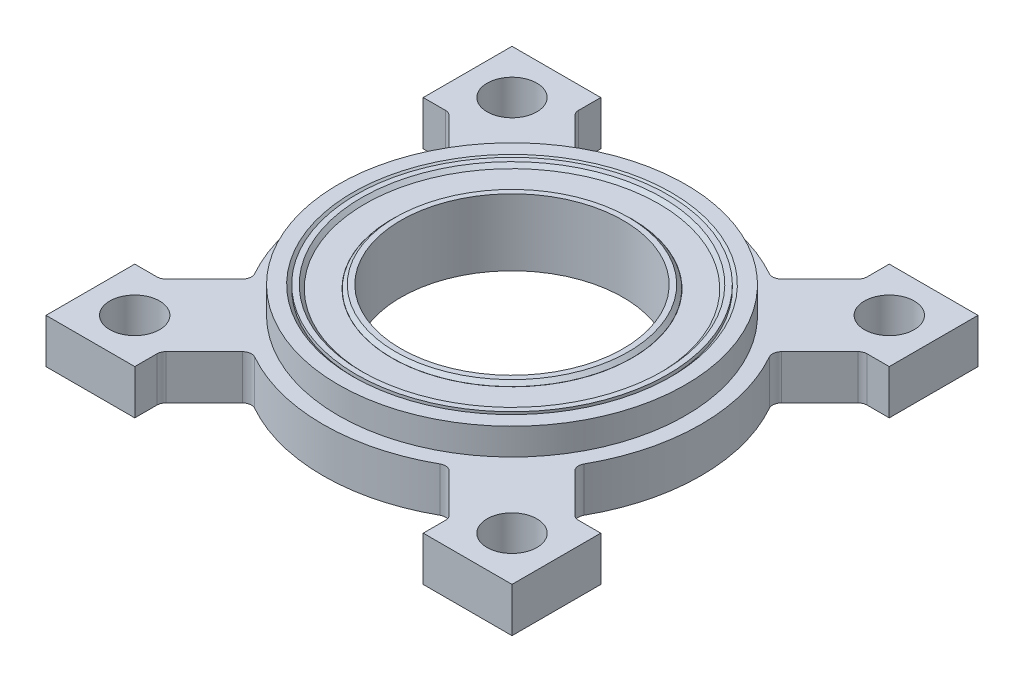
from build123d import *

# Parameters (mm, degrees)
SKETCH1_R           = 11.1252
SKETCH1_R_2         = 1.778
BOSS_EXTRUDE1_DEPTH = 3.175
SKETCH2_R           = 12.3952
SKETCH2_R_2         = 11.1252
BOSS_EXTRUDE2_DEPTH = 1.905
CHAMFER1_SIZE       = 0.254
SKETCH3_R           = 11.1252
SKETCH3_R_2         = 10.4902
BOSS_EXTRUDE3_DEPTH = 4.7625
CHAMFER2_SIZE       = 0.254
SKETCH4_R           = 10.4902
SKETCH4_R_2         = 8.5852
BOSS_EXTRUDE4_DEPTH = 4.2545
SKETCH5_R           = 8.5725
SKETCH5_R_2         = 7.9375
BOSS_EXTRUDE5_DEPTH = 4.7625
CHAMFER3_SIZE       = 0.254


with BuildPart() as part:
    # Sketch1 → Boss-Extrude1 (new body)
    with BuildSketch(Plane(origin=(0, 0, 0), x_dir=(1, 0, 0), z_dir=(0, 1, 0))):
        with BuildLine():
            Line((-10.2997, 16.637), (-10.2997, 15.052853673))
            ThreePointArc((-10.2997, 15.052853673), (-10.251363503, 14.809849693), (-10.113712806, 14.603840867))
            Line((-10.113712806, 14.603840867), (-7.028572367, 11.518700428))
            ThreePointArc((-7.028572367, 11.518700428), (-0.239648526, 13.491621757), (6.615059614, 11.761049076))
            ThreePointArc((6.615059614, 11.761049076), (7.012778636, 11.685418625), (7.375369343, 11.865497403))
            Line((7.375369343, 11.865497403), (10.113712806, 14.603840867))
            ThreePointArc((10.113712806, 14.603840867), (10.251363503, 14.809849693), (10.2997, 15.052853673))
            Line((10.2997, 15.052853673), (10.2997, 16.637))
            Line((10.2997, 16.637), (16.637, 16.637))
            Line((16.637, 16.637), (16.637, 10.2997))
            Line((16.637, 10.2997), (15.052853673, 10.2997))
            ThreePointArc((15.052853673, 10.2997), (14.809849693, 10.251363503), (14.603840867, 10.113712806))
            Line((14.603840867, 10.113712806), (11.865497403, 7.375369343))
            ThreePointArc((11.865497403, 7.375369343), (11.685418625, 7.012778636), (11.761049076, 6.615059614))
            ThreePointArc((11.761049076, 6.615059614), (13.49375, 0), (11.761049076, -6.615059614))
            ThreePointArc((11.761049076, -6.615059614), (11.685418625, -7.012778636), (11.865497403, -7.375369343))
            Line((11.865497403, -7.375369343), (14.603840867, -10.113712806))
            ThreePointArc((14.603840867, -10.113712806), (14.809849693, -10.251363503), (15.052853673, -10.2997))
            Line((15.052853673, -10.2997), (16.637, -10.2997))
            Line((16.637, -10.2997), (16.637, -16.637))
            Line((16.637, -16.637), (10.2997, -16.637))
            Line((10.2997, -16.637), (10.2997, -15.052853673))
            ThreePointArc((10.2997, -15.052853673), (10.251363503, -14.809849693), (10.113712806, -14.603840867))
            Line((10.113712806, -14.603840867), (7.375369343, -11.865497403))
            ThreePointArc((7.375369343, -11.865497403), (7.012778636, -11.685418625), (6.615059614, -11.761049076))
            ThreePointArc((6.615059614, -11.761049076), (0, -13.49375), (-6.615059614, -11.761049076))
            ThreePointArc((-6.615059614, -11.761049076), (-7.012778636, -11.685418625), (-7.375369343, -11.865497403))
            Line((-7.375369343, -11.865497403), (-10.113712806, -14.603840867))
            ThreePointArc((-10.113712806, -14.603840867), (-10.251363503, -14.809849693), (-10.2997, -15.052853673))
            Line((-10.2997, -15.052853673), (-10.2997, -16.637))
            Line((-10.2997, -16.637), (-16.637, -16.637))
            Line((-16.637, -16.637), (-16.637, -10.2997))
            Line((-16.637, -10.2997), (-15.052853673, -10.2997))
            ThreePointArc((-15.052853673, -10.2997), (-14.809849693, -10.251363503), (-14.603840867, -10.113712806))
            Line((-14.603840867, -10.113712806), (-11.865497403, -7.375369343))
            ThreePointArc((-11.865497403, -7.375369343), (-11.685418625, -7.012778636), (-11.761049076, -6.615059614))
            ThreePointArc((-11.761049076, -6.615059614), (-13.49375, 0), (-11.761049076, 6.615059614))
            ThreePointArc((-11.761049076, 6.615059614), (-11.685418625, 7.012778636), (-11.865497403, 7.375369343))
            Line((-11.865497403, 7.375369343), (-14.603840867, 10.113712806))
            ThreePointArc((-14.603840867, 10.113712806), (-14.809849693, 10.251363503), (-15.052853673, 10.2997))
            Line((-15.052853673, 10.2997), (-16.637, 10.2997))
            Line((-16.637, 10.2997), (-16.637, 16.637))
            Line((-16.637, 16.637), (-10.2997, 16.637))
        make_face()
        Circle(SKETCH1_R, mode=Mode.SUBTRACT)
        with Locations((-13.470384182, -13.470384182)):
            Circle(SKETCH1_R_2, mode=Mode.SUBTRACT)
        with Locations((-13.470384182, 13.470384182)):
            Circle(SKETCH1_R_2, mode=Mode.SUBTRACT)
        with Locations((13.470384182, 13.470384182)):
            Circle(SKETCH1_R_2, mode=Mode.SUBTRACT)
        with Locations((13.470384182, -13.470384182)):
            Circle(SKETCH1_R_2, mode=Mode.SUBTRACT)
    extrude(amount=BOSS_EXTRUDE1_DEPTH)

    # Sketch2 → Boss-Extrude2 (add)
    with BuildSketch(Plane(origin=(0, 3.175, 0), x_dir=(1, 0, 0), z_dir=(0, 1, 0))):
        Circle(SKETCH2_R)
        Circle(SKETCH2_R_2, mode=Mode.SUBTRACT)
    extrude(amount=BOSS_EXTRUDE2_DEPTH)

    # Chamfer1
    chamfer1_edges = [part.edges().sort_by_distance(p)[0] for p in [
        (-11.1252, 5.08, 0),
    ]]
    chamfer(chamfer1_edges, length=CHAMFER1_SIZE)

    # Sketch3 → Boss-Extrude3 (add)
    with BuildSketch(Plane(origin=(0, 5.08, 0), x_dir=(1, 0, 0), z_dir=(0, 1, 0))):
        Circle(SKETCH3_R)
        Circle(SKETCH3_R_2, mode=Mode.SUBTRACT)
    extrude(amount=-BOSS_EXTRUDE3_DEPTH)

    # Chamfer2
    chamfer2_edges = [part.edges().sort_by_distance(p)[0] for p in [
        (-10.4902, 0.3175, 0),
        (-10.4902, 5.08, 0),
    ]]
    chamfer(chamfer2_edges, length=CHAMFER2_SIZE)

    # Sketch4 → Boss-Extrude4 (add)
    with BuildSketch(Plane.XZ.offset(-4.826)):
        Circle(SKETCH4_R)
        Circle(SKETCH4_R_2, mode=Mode.SUBTRACT)
    extrude(amount=BOSS_EXTRUDE4_DEPTH)


with BuildPart() as body_2:
    # Sketch5 → Boss-Extrude5 (new body)
    with BuildSketch(Plane(origin=(0, 5.08, 0), x_dir=(1, 0, 0), z_dir=(0, 1, 0))):
        Circle(SKETCH5_R)
        Circle(SKETCH5_R_2, mode=Mode.SUBTRACT)
    extrude(amount=-BOSS_EXTRUDE5_DEPTH)

    # Chamfer3
    chamfer3_edges = [body_2.edges().sort_by_distance(p)[0] for p in [
        (-8.5725, 5.08, 0),
        (-8.5725, 0.3175, 0),
    ]]
    chamfer(chamfer3_edges, length=CHAMFER3_SIZE)


solid = Compound([part.part, body_2.part])
